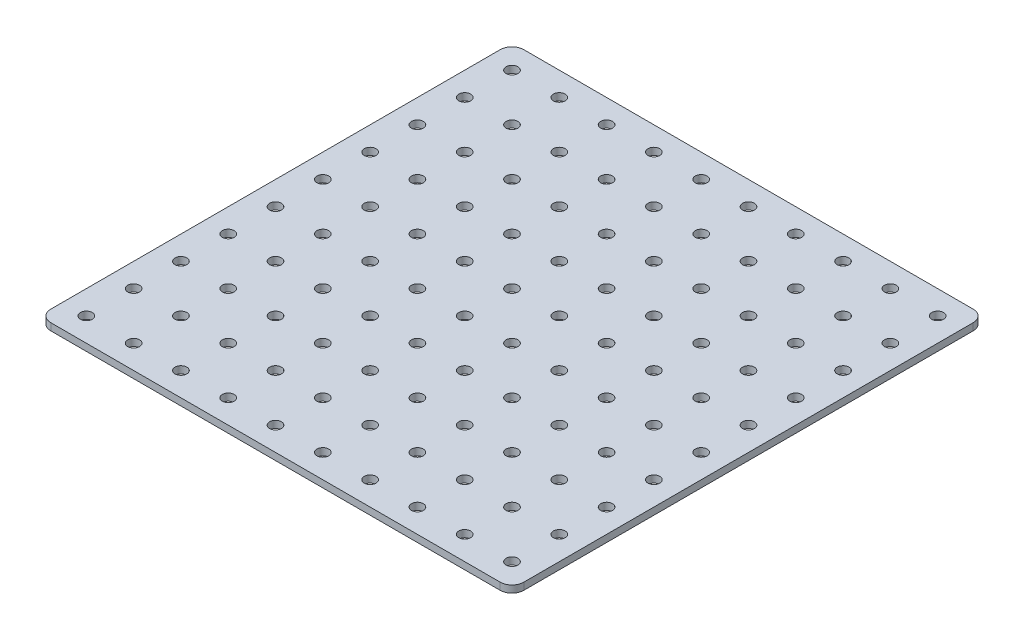
from build123d import *

# Parameters (mm, degrees)
SKETCH1_W            = 200
SKETCH1_H            = 200
BOSS_EXTRUDE1_DEPTH  = 3
SKETCH3_R            = 2.5
CUT_EXTRUDE1_DEPTH   = 4
LPATTERN1_COUNT      = 10
LPATTERN1_PITCH      = 20
LPATTERN1_COUNT_DIR2 = 10
LPATTERN1_PITCH_DIR2 = 20
FILLET1_R            = 5


with BuildPart() as part:
    # Sketch1 → Boss-Extrude1 (new body)
    with BuildSketch(Plane(origin=(0, 0, 0), x_dir=(1, 0, 0), z_dir=(0, 1, 0))):
        with Locations((100, 100)):
            Rectangle(SKETCH1_W, SKETCH1_H)
    extrude(amount=BOSS_EXTRUDE1_DEPTH)

    # Sketch3 → Cut-Extrude1 (cut, through all)
    with BuildSketch(Plane(origin=(0, 3, 0), x_dir=(1, 0, 0), z_dir=(0, 1, 0))):
        with Locations((190, 10)):
            Circle(SKETCH3_R)
    cut_extrude1 = extrude(amount=-CUT_EXTRUDE1_DEPTH, mode=Mode.SUBTRACT)

    # LPattern1: Cut-Extrude1 10 × 10
    with Locations(*[(-j * LPATTERN1_PITCH_DIR2, 0, -i * LPATTERN1_PITCH) for i in range(LPATTERN1_COUNT) for j in range(LPATTERN1_COUNT_DIR2) if (i, j) != (0, 0)]):
        add(cut_extrude1, mode=Mode.SUBTRACT)

    # Fillet1
    fillet1_edges = [part.edges().sort_by_distance(p)[0] for p in [
        (0, 1.5, -200),
        (200, 1.5, -200),
        (200, 1.5, 0),
        (0, 1.5, 0),
    ]]
    fillet(fillet1_edges, radius=FILLET1_R)


solid = part.part
